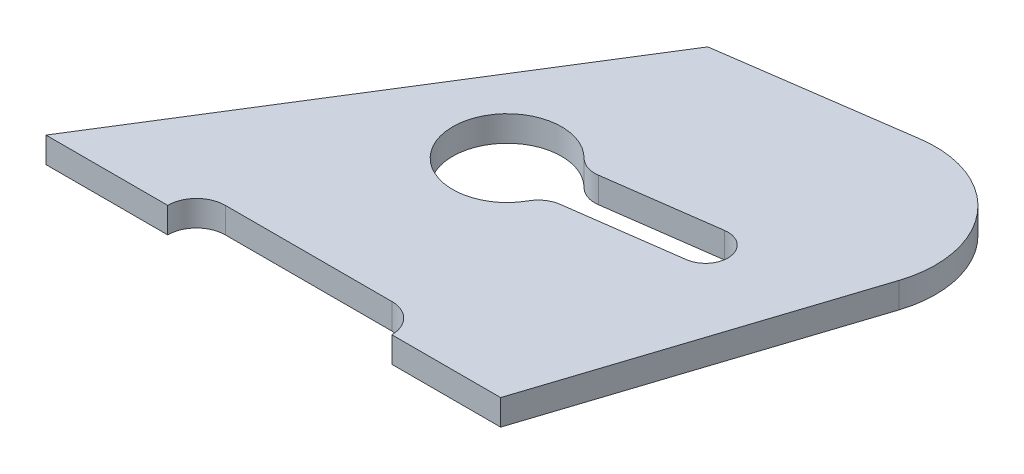
from build123d import *

# Parameters (mm, degrees)
BOSS_EXTRUDE1_DEPTH = 8


with BuildPart() as part:
    # Sketch1 → Boss-Extrude1 (new body)
    with BuildSketch(Plane(origin=(0, 0, 0), x_dir=(1, 0, 0), z_dir=(0, 1, 0))):
        with BuildLine():
            Line((0, 0), (38, 0))
            ThreePointArc((38, 0), (40.636038969, 6.363961031), (47, 9))
            Line((47, 9), (99, 9))
            ThreePointArc((99, 9), (105.363961031, 6.363961031), (108, 0))
            Line((108, 0), (142, 0))
            Line((142, 0), (172.50354814, 93.880267937))
            ThreePointArc((172.50354814, 93.880267937), (166.569139078, 124.354715336), (137.573015724, 135.451290736))
            Line((137.573015724, 135.451290736), (79.487889635, 127.207214423))
            Line((79.487889635, 127.207214423), (0, 0))
        make_face()
        with BuildLine():
            Line((97.109133521, 75.428206388), (131.785075785, 80.179945877))
            ThreePointArc((131.785075785, 80.179945877), (139.670612135, 74.195105322), (133.68577158, 66.309568971))
            Line((133.68577158, 66.309568971), (99.009829317, 61.557829483))
            ThreePointArc((99.009829317, 61.557829483), (95.579909698, 60.235342824), (93.103530342, 57.518568112))
            ThreePointArc((93.103530342, 57.518568112), (61.402056741, 63.469750476), (90.33394504, 77.729688746))
            ThreePointArc((90.33394504, 77.729688746), (93.449886138, 75.779245046), (97.109133521, 75.428206388))
        make_face(mode=Mode.SUBTRACT)
    extrude(amount=BOSS_EXTRUDE1_DEPTH)


solid = part.part
